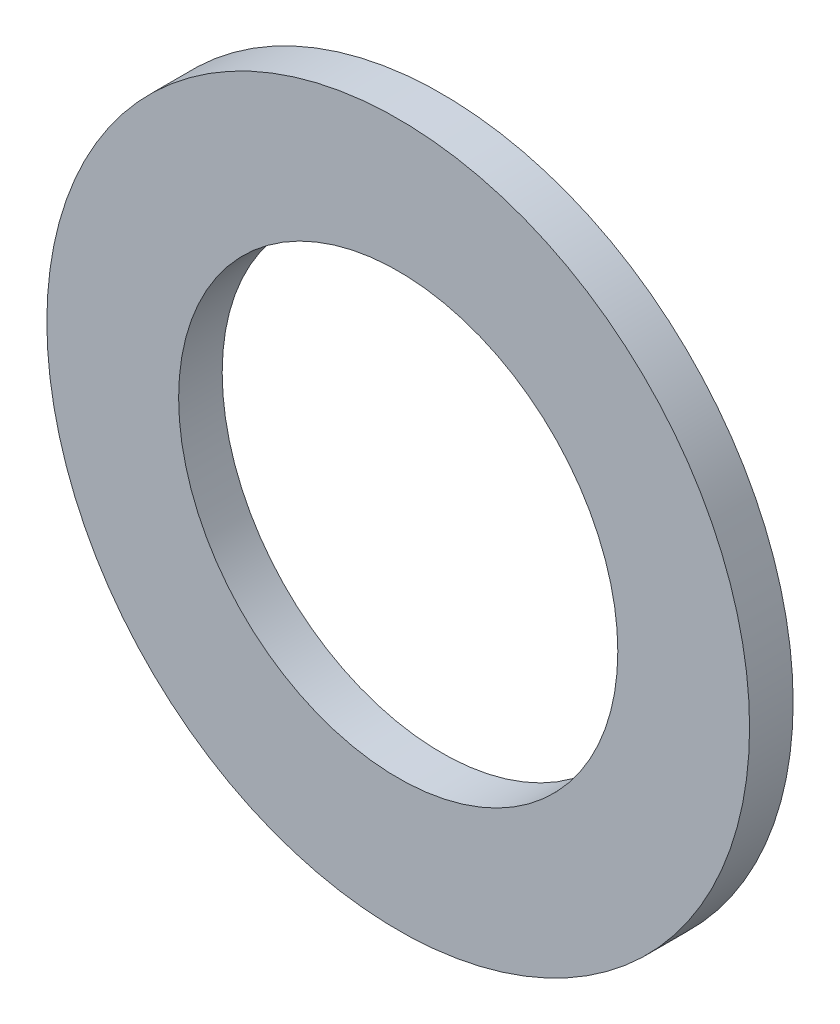
from build123d import *

# Parameters (mm, degrees)
SKETCH1_R           = 12.7
SKETCH1_R_2         = 7.9375
BOSS_EXTRUDE1_DEPTH = 1.5748


with BuildPart() as part:
    # Sketch1 → Boss-Extrude1 (new body)
    with BuildSketch(Plane.XY):
        Circle(SKETCH1_R)
        Circle(SKETCH1_R_2, mode=Mode.SUBTRACT)
    extrude(amount=BOSS_EXTRUDE1_DEPTH)


solid = part.part
